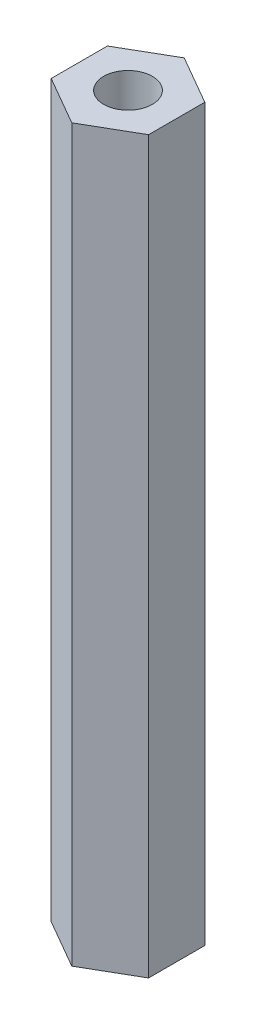
from build123d import *

# Parameters (mm, degrees)
SKETCH1_R           = 1.5
BOSS_EXTRUDE2_DEPTH = 45


with BuildPart() as part:
    # Sketch1 → Boss-Extrude2 (new body)
    with BuildSketch(Plane(origin=(0, 0, 0), x_dir=(1, 0, 0), z_dir=(0, 1, 0))):
        Polygon((3, -1.732050808), (3, 1.732050808), (0, 3.464101615), (-3, 1.732050808), (-3, -1.732050808), (0, -3.464101615), align=None)
        Circle(SKETCH1_R, mode=Mode.SUBTRACT)
    extrude(amount=BOSS_EXTRUDE2_DEPTH)


solid = part.part
